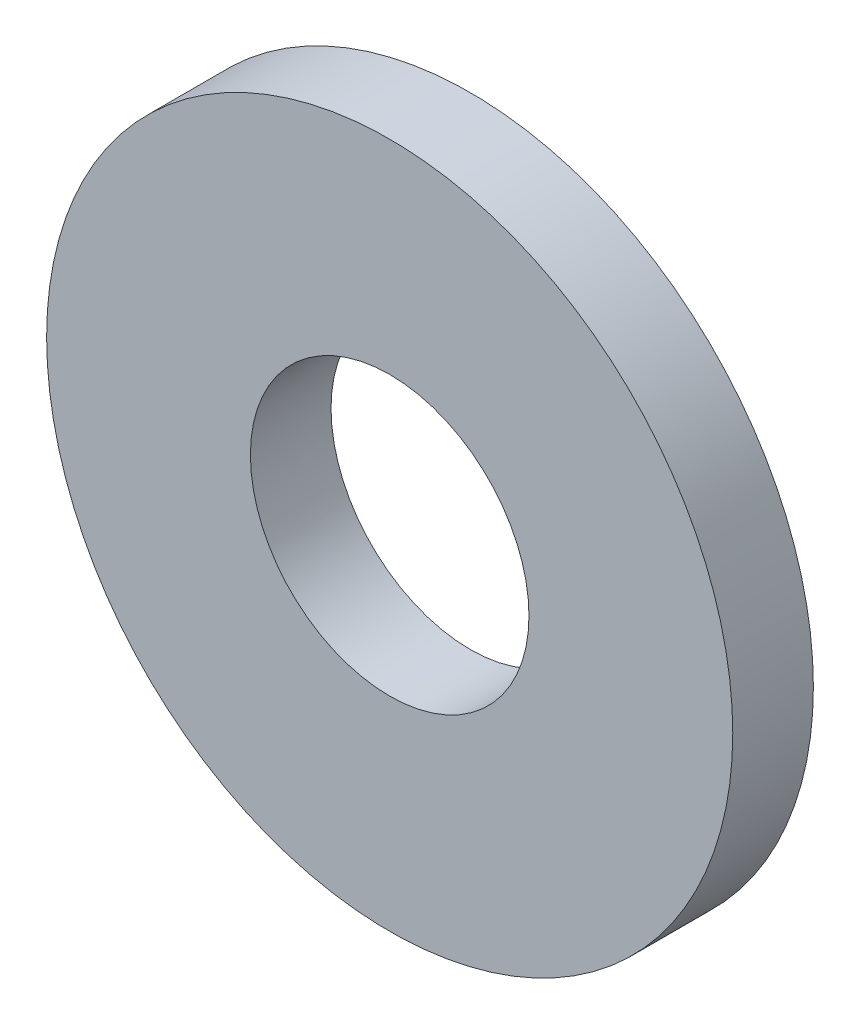
from build123d import *

# Parameters (mm, degrees)
SKETCH2_R           = 12.7
SKETCH2_R_2         = 5.1562
BOSS_EXTRUDE1_DEPTH = 1.49225


with BuildPart() as part:
    # Sketch2 → Boss-Extrude1 (new body, symmetric)
    with BuildSketch(Plane.XY):
        Circle(SKETCH2_R)
        Circle(SKETCH2_R_2, mode=Mode.SUBTRACT)
    extrude(amount=BOSS_EXTRUDE1_DEPTH, both=True)


solid = part.part
